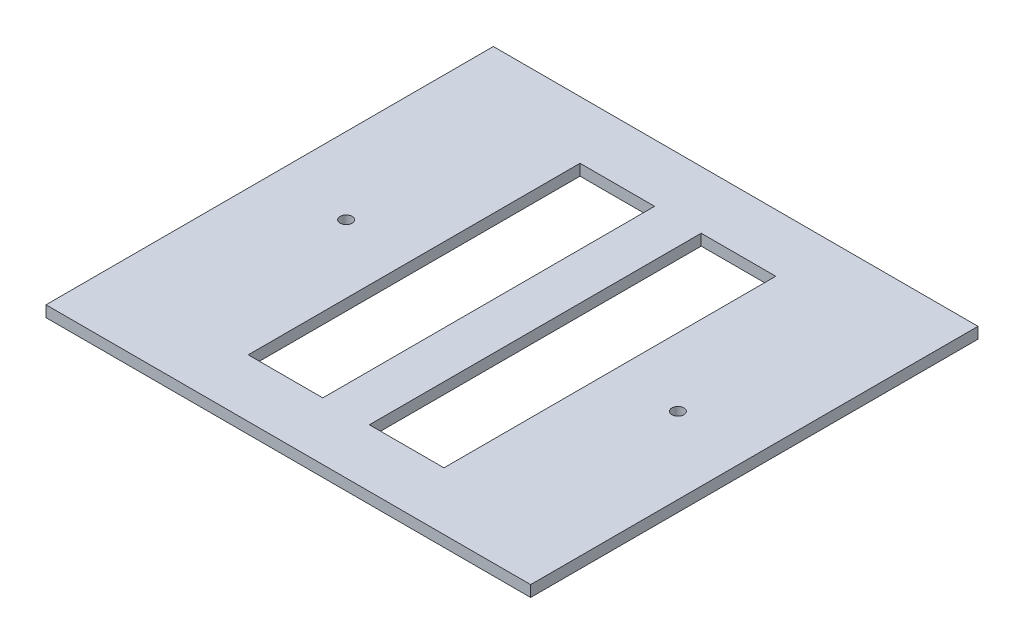
from build123d import *

# Parameters (mm, degrees)
SKETCH1_W           = 130
SKETCH1_H           = 120
BOSS_EXTRUDE1_DEPTH = 3
CUT_EXTRUDE1_START  = -4
SKETCH2_W           = 20
SKETCH2_H           = 89
CUT_EXTRUDE1_DEPTH  = 5
CUT_EXTRUDE2_START  = -4
SKETCH3_R           = 1.6
CUT_EXTRUDE2_DEPTH  = 5


with BuildPart() as part:
    # Sketch1 → Boss-Extrude1 (new body)
    with BuildSketch(Plane(origin=(0, 0, 0), x_dir=(1, 0, 0), z_dir=(0, 1, 0))):
        Rectangle(SKETCH1_W, SKETCH1_H)
    extrude(amount=BOSS_EXTRUDE1_DEPTH)

    # Sketch2 → Cut-Extrude1 (cut)
    with BuildSketch(Plane(origin=(0, 3, 0), x_dir=(1, 0, 0), z_dir=(0, 1, 0)).offset(CUT_EXTRUDE1_START)):
        with Locations((-16.25, 0)):
            Rectangle(SKETCH2_W, SKETCH2_H)
    cut_extrude1 = extrude(amount=CUT_EXTRUDE1_DEPTH, mode=Mode.SUBTRACT)

    # Mirror1: Cut-Extrude1 across plane
    add(cut_extrude1.mirror(Plane(origin=(0, 0, 0), x_dir=(0, 0, 1), z_dir=(1, 0, 0))), mode=Mode.SUBTRACT)

    # Sketch3 → Cut-Extrude2 (cut)
    with BuildSketch(Plane(origin=(0, 3, 0), x_dir=(1, 0, 0), z_dir=(0, 1, 0)).offset(CUT_EXTRUDE2_START)):
        with Locations((44.5, 0)):
            Circle(SKETCH3_R)
    cut_extrude2 = extrude(amount=CUT_EXTRUDE2_DEPTH, mode=Mode.SUBTRACT)

    # Mirror2: Cut-Extrude2 across plane
    add(cut_extrude2.mirror(Plane(origin=(0, 0, 0), x_dir=(0, 0, 1), z_dir=(1, 0, 0))), mode=Mode.SUBTRACT)


solid = part.part
